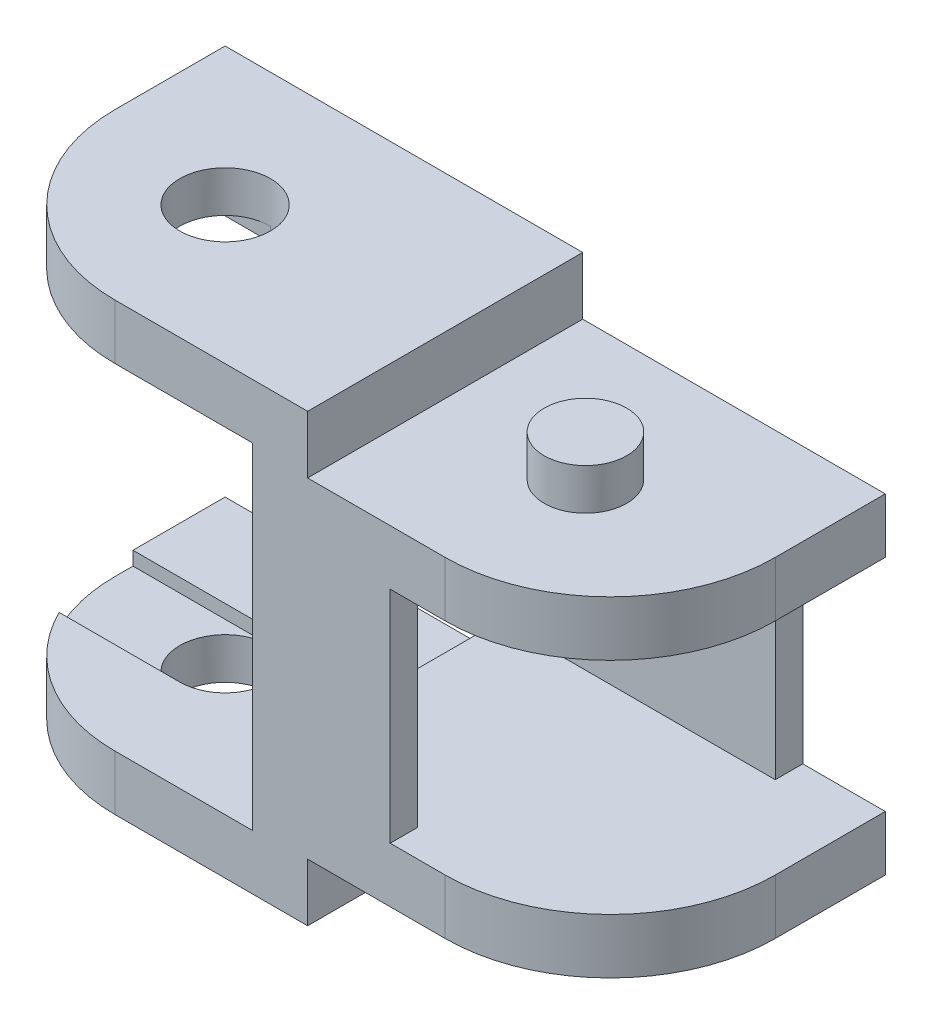
from build123d import *

# Parameters (mm, degrees)
EXTRUDE_2_DEPTH     = 10
SKETCH_3_R          = 1.5
EXTRUDE_3_DEPTH     = 1.5
SKETCH_5_R          = 1.65
CUT_EXTRUDE_2_DEPTH = 3
FILLET_1_R          = 6
SKETCH_6_W          = 10
SKETCH_6_H          = 1
SKETCH_6_W_2        = 5
EXTRUDE_4_DEPTH     = 4
SKETCH_7_W          = 5.689599517
SKETCH_7_H          = 3.3
CUT_EXTRUDE_3_DEPTH = 0.5


with BuildPart() as part:
    # Эскиз2 → Бобышка-Вытянуть2 (new body)
    with BuildSketch(Plane.XY):
        Polygon((0, 0), (0, 2), (13, 2), (13, -0.1), (24, -0.1), (24, -2.1), (11, -2.1), (11, 0), align=None)
    extrude(amount=EXTRUDE_2_DEPTH)

    # Эскиз3 → Бобышка-Вытянуть3 (add)
    with BuildSketch(Plane(origin=(0, -0.1, 0), x_dir=(1, 0, 0), z_dir=(0, 1, 0))):
        with Locations((18.1, -5)):
            Circle(SKETCH_3_R)
    extrude(amount=EXTRUDE_3_DEPTH)

    # Эскиз5 → Вырез-Вытянуть2 (cut, through all)
    with BuildSketch(Plane.XZ):
        with Locations((5, 5)):
            Circle(SKETCH_5_R)
    extrude(amount=-CUT_EXTRUDE_2_DEPTH, mode=Mode.SUBTRACT)

    # Скругление1
    fillet_1_edges = [part.edges().sort_by_distance(p)[0] for p in [
        (24, -1.1, 10),
        (0, 1, 10),
    ]]
    fillet(fillet_1_edges, radius=FILLET_1_R)

    # Эскиз6 → Бобышка-Вытянуть4 (add)
    with BuildSketch(Plane(origin=(0, -2.1, 0), x_dir=(-1, 0, 0), z_dir=(0, -1, 0))):
        with Locations((-16, -0.5)):
            Rectangle(SKETCH_6_W, SKETCH_6_H)
        with Locations((-13.5, -9.5)):
            Rectangle(SKETCH_6_W_2, SKETCH_6_H)
    extrude(amount=EXTRUDE_4_DEPTH)

    # Эскиз7 → Вырез-Вытянуть3 (cut)
    with BuildSketch(Plane.XZ):
        with Locations((2.155200242, 5)):
            Rectangle(SKETCH_7_W, SKETCH_7_H)
    extrude(amount=-CUT_EXTRUDE_3_DEPTH, mode=Mode.SUBTRACT)

    # Зеркальное отражение1: part across plane


with BuildPart() as part_1:
    add(part.part)
    add(part.part.mirror(Plane.ZX.offset(-6.1)))


solid = part_1.part
